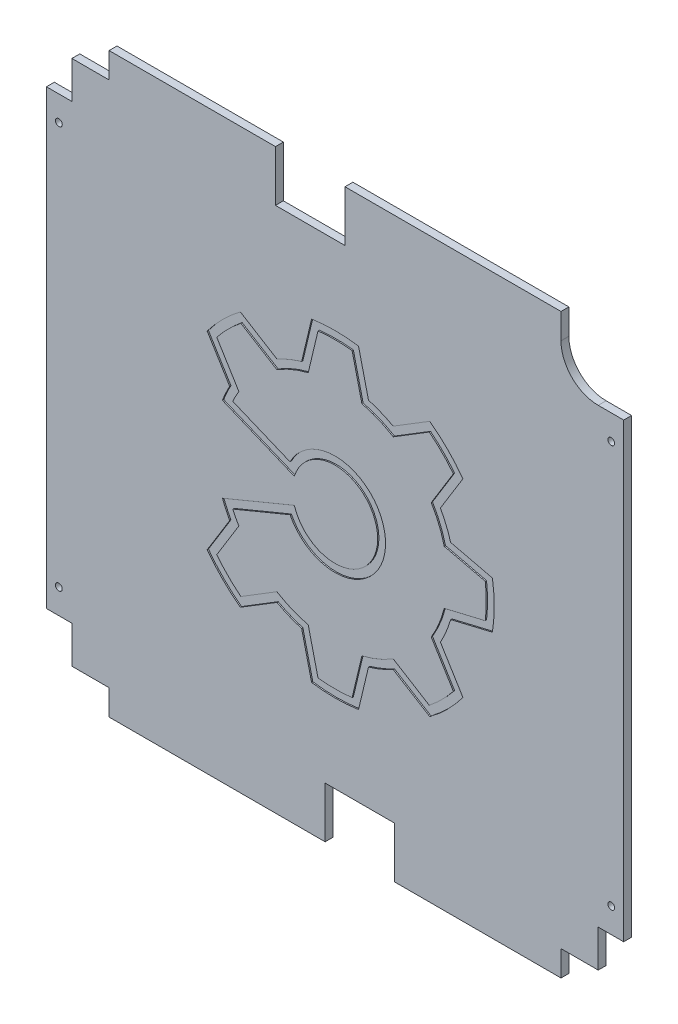
from build123d import *

# Parameters (mm, degrees)
SKETCH1_R           = 2.75
BOSS_EXTRUDE1_DEPTH = 6.35
CUT_EXTRUDE1_DEPTH  = 6.35
CUT_EXTRUDE2_DEPTH  = 1


with BuildPart() as part:
    # Sketch1 → Boss-Extrude1 (new body)
    with BuildSketch(Plane.XY):
        Polygon((182, -212), (212, -212), (212, -182), (232.5, -182), (232.5, 0), (232.5, 182), (212, 182), (212, 212), (182, 212), (182, 232.5), (8, 232.5), (8, 191.5), (-48, 191.5), (-48, 232.5), (-182, 232.5), (-182, 212), (-212, 212), (-212, 182), (-232.5, 182), (-232.5, 0), (-232.5, -182), (-212, -182), (-212, -212), (-182, -212), (-182, -232.5), (-8, -232.5), (-8, -191.5), (48, -191.5), (48, -232.5), (182, -232.5), align=None)
        with Locations((-222.5, -162)):
            Circle(SKETCH1_R, mode=Mode.SUBTRACT)
        with Locations((222.5, -162)):
            Circle(SKETCH1_R, mode=Mode.SUBTRACT)
        with Locations((222.5, 162)):
            Circle(SKETCH1_R, mode=Mode.SUBTRACT)
        with Locations((-222.5, 162)):
            Circle(SKETCH1_R, mode=Mode.SUBTRACT)
    extrude(amount=BOSS_EXTRUDE1_DEPTH)

    # Sketch2 → Cut-Extrude1 (cut)
    with BuildSketch(Plane.XY.offset(6.35)):
        with BuildLine():
            Line((212, 212), (182, 212))
            ThreePointArc((182, 212), (190.786796564, 190.786796564), (212, 182))
            Line((212, 182), (212, 212))
        make_face()
    extrude(amount=-CUT_EXTRUDE1_DEPTH, mode=Mode.SUBTRACT)

    # Sketch3 → Cut-Extrude2 (cut)
    with BuildSketch(Plane.XY.offset(6.35)):
        with BuildLine():
            Line((-90.71398693, 34.138368447), (-32.791230158, 10.145977022))
            ThreePointArc((-32.791230158, 10.145977022), (34.325, 0), (-32.791230158, -10.145977022))
            Line((-32.791230158, -10.145977022), (-90.71398693, -34.138368447))
            ThreePointArc((-90.71398693, -34.138368447), (-88.022539954, -40.576940312), (-84.874800654, -46.805168935))
            Line((-84.874800654, -46.805168935), (-103.008511577, -76.276321146))
            ThreePointArc((-103.008511577, -76.276321146), (-90.633411679, -90.633411679), (-76.276321146, -103.008511577))
            Line((-76.276321146, -103.008511577), (-46.805168935, -84.874800654))
            ThreePointArc((-46.805168935, -84.874800654), (-37.091591682, -89.547023689), (-26.919294746, -93.111799442))
            Line((-26.919294746, -93.111799442), (-18.90251313, -126.773520983))
            ThreePointArc((-18.90251313, -126.773520983), (0, -128.175), (18.90251313, -126.773520983))
            Line((18.90251313, -126.773520983), (26.919294746, -93.111799442))
            ThreePointArc((26.919294746, -93.111799442), (37.091591682, -89.547023689), (46.805168935, -84.874800654))
            Line((46.805168935, -84.874800654), (76.276321146, -103.008511577))
            ThreePointArc((76.276321146, -103.008511577), (90.633411679, -90.633411679), (103.008511577, -76.276321146))
            Line((103.008511577, -76.276321146), (84.874800654, -46.805168935))
            ThreePointArc((84.874800654, -46.805168935), (89.547023689, -37.091591682), (93.111799442, -26.919294746))
            Line((93.111799442, -26.919294746), (126.773520983, -18.90251313))
            ThreePointArc((126.773520983, -18.90251313), (128.175, 0), (126.773520983, 18.90251313))
            Line((126.773520983, 18.90251313), (93.111799442, 26.919294746))
            ThreePointArc((93.111799442, 26.919294746), (89.547023689, 37.091591682), (84.874800654, 46.805168935))
            Line((84.874800654, 46.805168935), (103.008511577, 76.276321146))
            ThreePointArc((103.008511577, 76.276321146), (90.633411679, 90.633411679), (76.276321146, 103.008511577))
            Line((76.276321146, 103.008511577), (46.805168935, 84.874800654))
            ThreePointArc((46.805168935, 84.874800654), (37.091591682, 89.547023689), (26.919294746, 93.111799442))
            Line((26.919294746, 93.111799442), (18.90251313, 126.773520983))
            ThreePointArc((18.90251313, 126.773520983), (0, 128.175), (-18.90251313, 126.773520983))
            Line((-18.90251313, 126.773520983), (-26.919294746, 93.111799442))
            ThreePointArc((-26.919294746, 93.111799442), (-37.091591682, 89.547023689), (-46.805168935, 84.874800654))
            Line((-46.805168935, 84.874800654), (-76.276321146, 103.008511577))
            ThreePointArc((-76.276321146, 103.008511577), (-90.633411679, 90.633411679), (-103.008511577, 76.276321146))
            Line((-103.008511577, 76.276321146), (-84.874800654, 46.805168935))
            ThreePointArc((-84.874800654, 46.805168935), (-88.022539954, 40.576940312), (-90.71398693, 34.138368447))
        make_face()
        with BuildLine():
            Line((-82.41394096, 37.57356731), (-36.249121046, 18.451472797))
            ThreePointArc((-36.249121046, 18.451472797), (40.675, 0), (-36.249121046, -18.451472797))
            Line((-36.249121046, -18.451472797), (-82.41394096, -37.57356731))
            ThreePointArc((-82.41394096, -37.57356731), (-80.084171036, -42.312600659), (-77.482180911, -46.907806027))
            Line((-77.482180911, -46.907806027), (-95.308362806, -75.879157904))
            ThreePointArc((-95.308362806, -75.879157904), (-86.143283618, -86.143283618), (-75.879157904, -95.308362806))
            Line((-75.879157904, -95.308362806), (-46.907806027, -77.482180911))
            ThreePointArc((-46.907806027, -77.482180911), (-34.661551886, -83.680388657), (-21.619347811, -87.957003276))
            Line((-21.619347811, -87.957003276), (-13.73852254, -121.047856749))
            ThreePointArc((-13.73852254, -121.047856749), (0, -121.825), (13.73852254, -121.047856749))
            Line((13.73852254, -121.047856749), (21.619347811, -87.957003276))
            ThreePointArc((21.619347811, -87.957003276), (34.661551886, -83.680388657), (46.907806027, -77.482180911))
            Line((46.907806027, -77.482180911), (75.879157904, -95.308362806))
            ThreePointArc((75.879157904, -95.308362806), (86.143283618, -86.143283618), (95.308362806, -75.879157904))
            Line((95.308362806, -75.879157904), (77.482180911, -46.907806027))
            ThreePointArc((77.482180911, -46.907806027), (83.680388657, -34.661551886), (87.957003276, -21.619347811))
            Line((87.957003276, -21.619347811), (121.047856749, -13.73852254))
            ThreePointArc((121.047856749, -13.73852254), (121.825, 0), (121.047856749, 13.73852254))
            Line((121.047856749, 13.73852254), (87.957003276, 21.619347811))
            ThreePointArc((87.957003276, 21.619347811), (83.680388657, 34.661551886), (77.482180911, 46.907806027))
            Line((77.482180911, 46.907806027), (95.308362806, 75.879157904))
            ThreePointArc((95.308362806, 75.879157904), (86.143283618, 86.143283618), (75.879157904, 95.308362806))
            Line((75.879157904, 95.308362806), (46.907806027, 77.482180911))
            ThreePointArc((46.907806027, 77.482180911), (34.661551886, 83.680388657), (21.619347811, 87.957003276))
            Line((21.619347811, 87.957003276), (13.73852254, 121.047856749))
            ThreePointArc((13.73852254, 121.047856749), (0, 121.825), (-13.73852254, 121.047856749))
            Line((-13.73852254, 121.047856749), (-21.619347811, 87.957003276))
            ThreePointArc((-21.619347811, 87.957003276), (-34.661551886, 83.680388657), (-46.907806027, 77.482180911))
            Line((-46.907806027, 77.482180911), (-75.879157904, 95.308362806))
            ThreePointArc((-75.879157904, 95.308362806), (-86.143283618, 86.143283618), (-95.308362806, 75.879157904))
            Line((-95.308362806, 75.879157904), (-77.482180911, 46.907806027))
            ThreePointArc((-77.482180911, 46.907806027), (-80.084171036, 42.312600659), (-82.41394096, 37.57356731))
        make_face(mode=Mode.SUBTRACT)
    extrude(amount=-CUT_EXTRUDE2_DEPTH, mode=Mode.SUBTRACT)


solid = part.part
